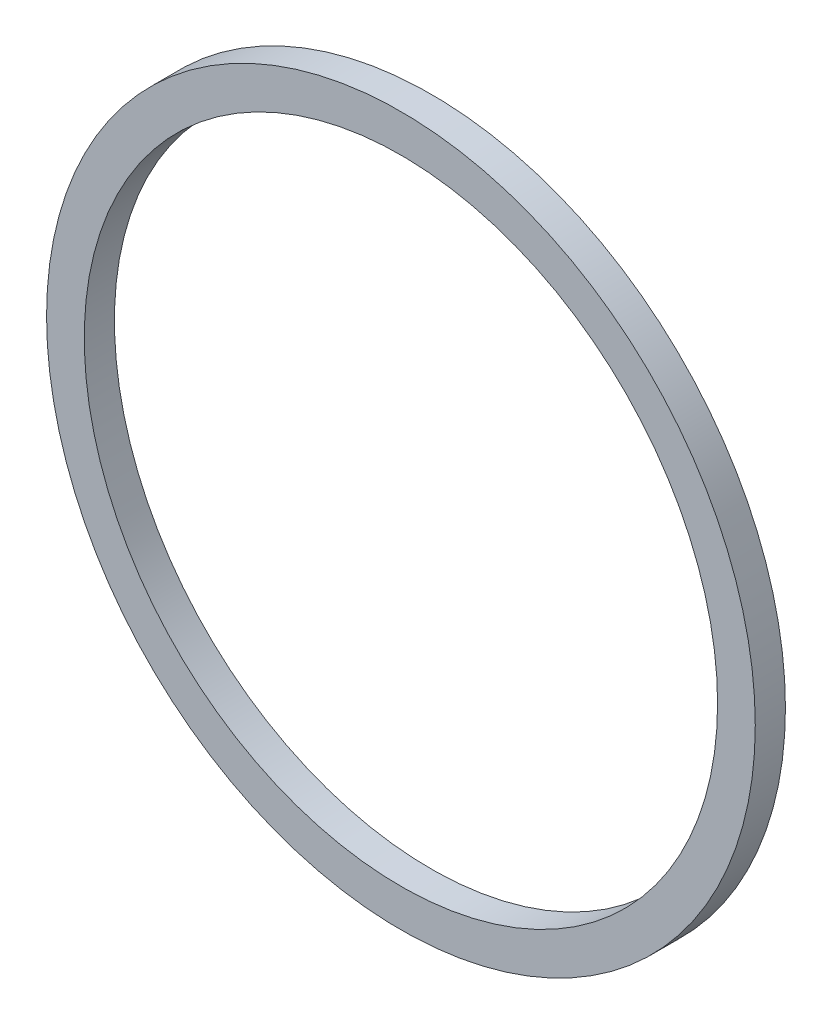
from build123d import *

# Parameters (mm, degrees)
SKETCH_1_R      = 23.5
SKETCH_1_R_2    = 21
EXTRUDE_1_DEPTH = 2


with BuildPart() as part:
    # 草图1 → 凸台-拉伸1 (new body)
    with BuildSketch(Plane.XY):
        Circle(SKETCH_1_R)
        Circle(SKETCH_1_R_2, mode=Mode.SUBTRACT)
    extrude(amount=EXTRUDE_1_DEPTH)


solid = part.part
